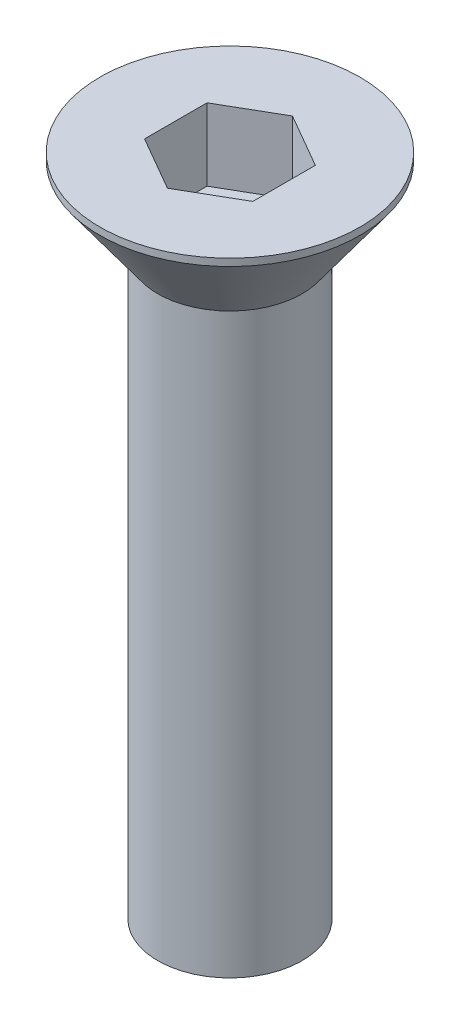
from build123d import *

# Parameters (mm, degrees)
CUT_EXTRUDE_1_DEPTH = 1
SKETCH_3_R          = 1
EXTRUDE_2_DEPTH     = 8


with BuildPart() as part:
    # 草图1 → 旋转1 (revolve)
    with BuildSketch(Plane.XY):
        Polygon((0, -1.2), (0, 0), (1.8, 0), (1.8, -0.1), (1, -1.2), align=None)
    revolve(axis=Axis((0, 0, 0), (0, 1, 0)))

    # 草图2 → 切除-拉伸1 (cut)
    with BuildSketch(Plane(origin=(0, 0, 0), x_dir=(1, 0, 0), z_dir=(0, 1, 0))):
        Polygon((0, -0.866025404), (0.75, -0.433012702), (0.75, 0.433012702), (0, 0.866025404), (-0.75, 0.433012702), (-0.75, -0.433012702), align=None)
    extrude(amount=-CUT_EXTRUDE_1_DEPTH, mode=Mode.SUBTRACT)

    # 草图3 → 凸台-拉伸2 (add)
    with BuildSketch(Plane.XZ.offset(1.2)):
        Circle(SKETCH_3_R)
    extrude(amount=EXTRUDE_2_DEPTH)


solid = part.part
